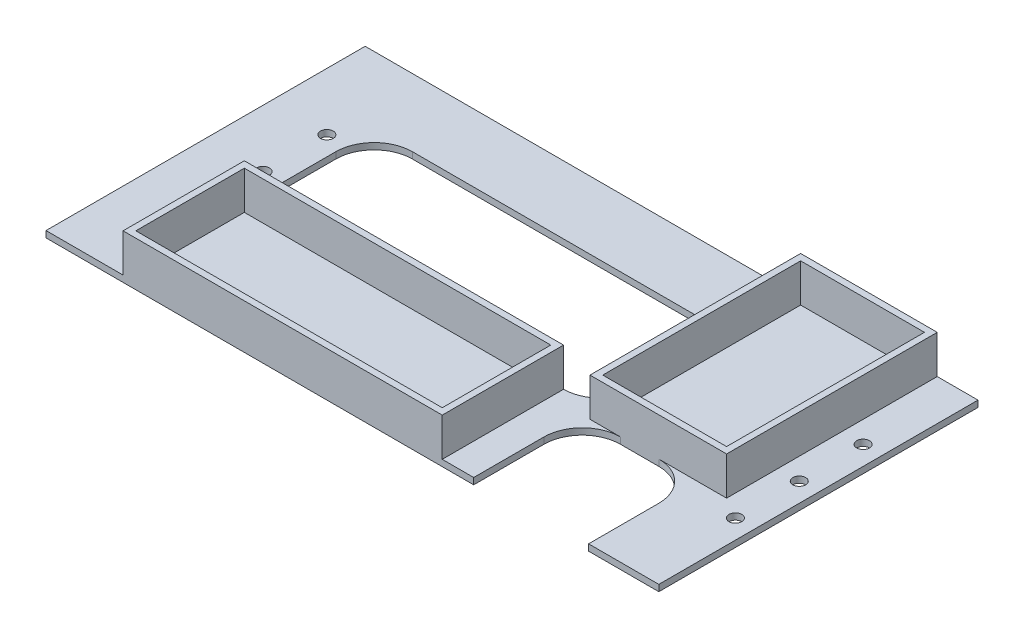
from build123d import *

# Parameters (mm, degrees)
SKETCH1_W           = 450
SKETCH1_H           = 250
BOSS_EXTRUDE1_DEPTH = 5
CUT_EXTRUDE1_DEPTH  = 10
SKETCH3_W           = 250
SKETCH3_H           = 5
BOSS_EXTRUDE2_DEPTH = 30
SKETCH4_R           = 5
CUT_EXTRUDE2_DEPTH  = 30
SKETCH5_W           = 107
SKETCH5_H           = 165
SKETCH5_W_2         = 97
SKETCH5_H_2         = 155
SKETCH5_W_3         = 250
SKETCH5_H_3         = 95.00223246
SKETCH5_W_4         = 240
SKETCH5_H_4         = 85.00223246
BOSS_EXTRUDE3_DEPTH = 30


with BuildPart() as part:
    # Sketch1 → Boss-Extrude1 (new body)
    with BuildSketch(Plane(origin=(0, 0, 0), x_dir=(1, 0, 0), z_dir=(0, 1, 0))):
        Rectangle(SKETCH1_W, SKETCH1_H)
    extrude(amount=BOSS_EXTRUDE1_DEPTH)

    # Sketch2 → Cut-Extrude1 (cut)
    with BuildSketch(Plane(origin=(0, 5, 0), x_dir=(1, 0, 0), z_dir=(0, 1, 0))):
        with BuildLine():
            Line((-165, 72), (55, 72))
            ThreePointArc((55, 72), (76.213203436, 63.213203436), (85, 42))
            Line((85, 42), (85, 0))
            ThreePointArc((85, 0), (76.213203436, -21.213203436), (55, -30))
            Line((55, -30), (-165, -30))
            ThreePointArc((-165, -30), (-186.213203436, -21.213203436), (-195, 0))
            Line((-195, 0), (-195, 42))
            ThreePointArc((-195, 42), (-186.213203436, 63.213203436), (-165, 72))
        make_face()
        with BuildLine():
            Line((110, -40), (140, -40))
            ThreePointArc((140, -40), (161.213203436, -48.786796564), (170, -70))
            Line((170, -70), (170, -125))
            Line((170, -125), (80, -125))
            Line((80, -125), (80, -70))
            ThreePointArc((80, -70), (88.786796564, -48.786796564), (110, -40))
        make_face()
    extrude(amount=-CUT_EXTRUDE1_DEPTH, mode=Mode.SUBTRACT)

    # Sketch3 → Boss-Extrude2 (add)
    with BuildSketch(Plane.ZY.offset(225)):
        with Locations((0, 2.5)):
            Rectangle(SKETCH3_W, SKETCH3_H)
    extrude(amount=BOSS_EXTRUDE2_DEPTH)

    # Sketch4 → Cut-Extrude2 (cut)
    with BuildSketch(Plane(origin=(0, 5, 0), x_dir=(1, 0, 0), z_dir=(0, 1, 0))):
        with Locations((210, 0)):
            Circle(SKETCH4_R)
        with Locations((210, 50)):
            Circle(SKETCH4_R)
        with Locations((210, -50)):
            Circle(SKETCH4_R)
        with Locations((-210, -50)):
            Circle(SKETCH4_R)
        with Locations((-210, 0)):
            Circle(SKETCH4_R)
        with Locations((-210, 50)):
            Circle(SKETCH4_R)
    extrude(amount=-CUT_EXTRUDE2_DEPTH, mode=Mode.SUBTRACT)

    # Sketch5 → Boss-Extrude3 (add)
    with BuildSketch(Plane(origin=(0, 5, 0), x_dir=(1, 0, 0), z_dir=(0, 1, 0))):
        with Locations((139.576867422, 42.5)):
            Rectangle(SKETCH5_W, SKETCH5_H)
        with Locations((139.576867422, 42.5)):
            Rectangle(SKETCH5_W_2, SKETCH5_H_2, mode=Mode.SUBTRACT)
        with Locations((-69.634018269, -77.49888377)):
            Rectangle(SKETCH5_W_3, SKETCH5_H_3)
        with Locations((-69.634018269, -77.49888377)):
            Rectangle(SKETCH5_W_4, SKETCH5_H_4, mode=Mode.SUBTRACT)
    extrude(amount=BOSS_EXTRUDE3_DEPTH)


solid = part.part
